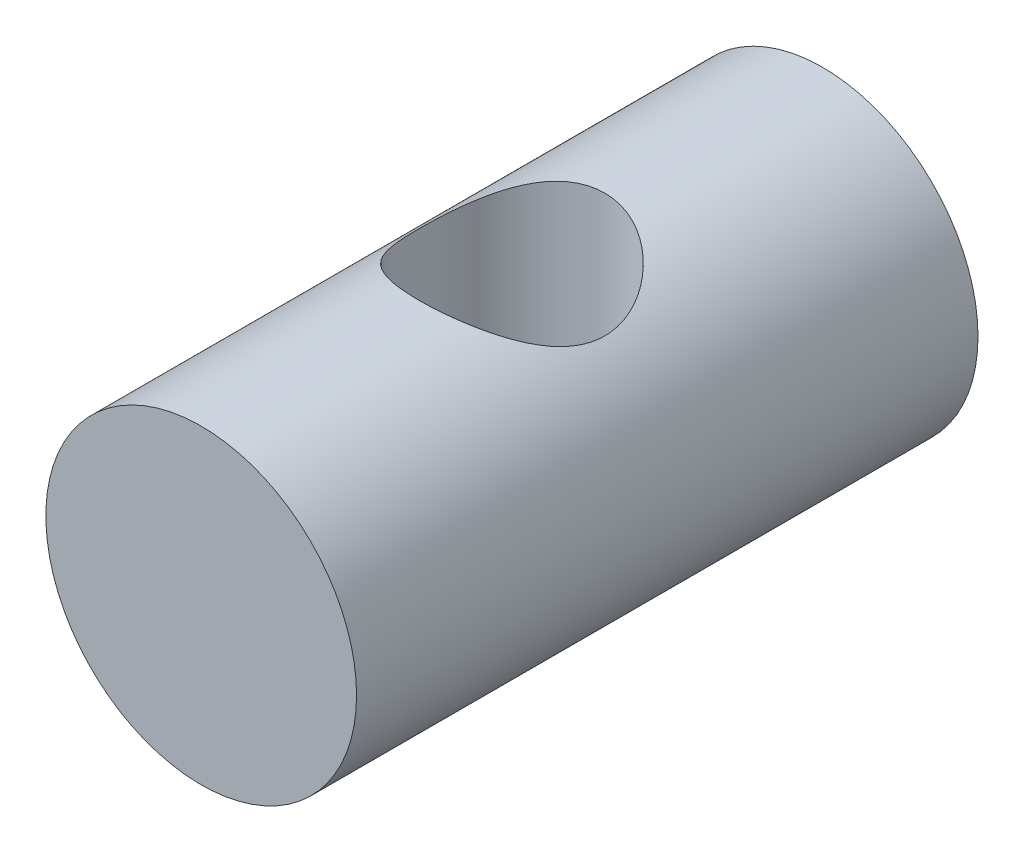
from build123d import *

# Parameters (mm, degrees)
SKETCH1_R              = 3.175
BOSS_EXTRUDE1_DEPTH    = 12.7
F_10_24_TAPPED_HOLE2_D = 3.7973


with BuildPart() as part:
    # Sketch1 → Boss-Extrude1 (new body)
    with BuildSketch(Plane.XY):
        Circle(SKETCH1_R)
    extrude(amount=BOSS_EXTRUDE1_DEPTH)

    # #10-24 Tapped Hole2 (through all)
    with Locations(Plane(origin=(0, 3.175, 6.35), x_dir=(1, 0, 0), z_dir=(0, 1, 0))):
        with Locations((0, 0)):
            Hole(F_10_24_TAPPED_HOLE2_D / 2)


solid = part.part
